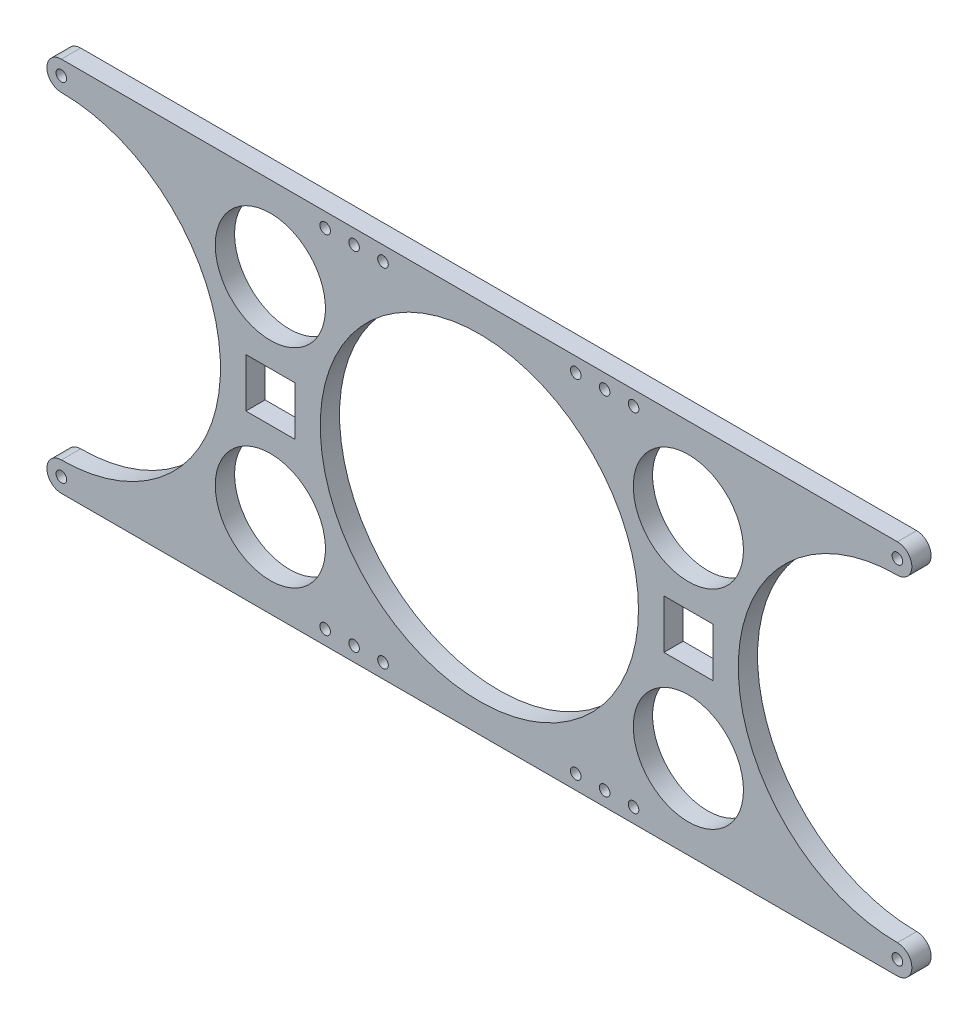
from build123d import *

# Parameters (mm, degrees)
SKETCH1_R            = 82.55
SKETCH1_R_2          = 28.575
SKETCH1_W            = 25.4
SKETCH1_H            = 25.4
BOSS_EXTRUDE1_DEPTH  = 5
M5_CLEARANCE_HOLE1_D = 5.5


with BuildPart() as part:
    # Sketch1 → Boss-Extrude1 (new body, symmetric)
    with BuildSketch(Plane.XY):
        with BuildLine():
            Line((-216.868301049, 97.55), (216.868301049, 97.55))
            ThreePointArc((216.868301049, 97.55), (224.368301049, 90.05), (216.868301049, 82.55))
            ThreePointArc((216.868301049, 82.55), (134.318301049, 0), (216.868301049, -82.55))
            ThreePointArc((216.868301049, -82.55), (224.368301049, -90.05), (216.868301049, -97.55))
            Line((216.868301049, -97.55), (-216.868301049, -97.55))
            ThreePointArc((-216.868301049, -97.55), (-224.368301049, -90.05), (-216.868301049, -82.55))
            ThreePointArc((-216.868301049, -82.55), (-134.318301049, 0), (-216.868301049, 82.55))
            ThreePointArc((-216.868301049, 82.55), (-224.368301049, 90.05), (-216.868301049, 97.55))
        make_face()
        Circle(SKETCH1_R, mode=Mode.SUBTRACT)
        with Locations((108.434150525, 53.975)):
            Circle(SKETCH1_R_2, mode=Mode.SUBTRACT)
        with Locations((108.434150525, -53.975)):
            Circle(SKETCH1_R_2, mode=Mode.SUBTRACT)
        with Locations((-108.434150525, -53.975)):
            Circle(SKETCH1_R_2, mode=Mode.SUBTRACT)
        with Locations((-108.434150525, 53.975)):
            Circle(SKETCH1_R_2, mode=Mode.SUBTRACT)
        with Locations((-108.434150525, 0)):
            Rectangle(SKETCH1_W, SKETCH1_H, mode=Mode.SUBTRACT)
        with Locations((108.434150525, 0)):
            Rectangle(SKETCH1_W, SKETCH1_H, mode=Mode.SUBTRACT)
    extrude(amount=BOSS_EXTRUDE1_DEPTH, both=True)

    # M5 Clearance Hole1 (through all)
    with Locations(Plane.XY.offset(5)):
        with Locations((-80, 90.05), (-65, 90.05), (-50, 90.05), (50, 90.05), (65, 90.05), (80, 90.05), (-80, -90.05), (-65, -90.05), (-50, -90.05), (50, -90.05), (65, -90.05), (80, -90.05), (-216.868301049, 90.05), (216.868301049, 90.05), (-216.868301049, -90.05), (216.868301049, -90.05)):
            Hole(M5_CLEARANCE_HOLE1_D / 2)


solid = part.part
